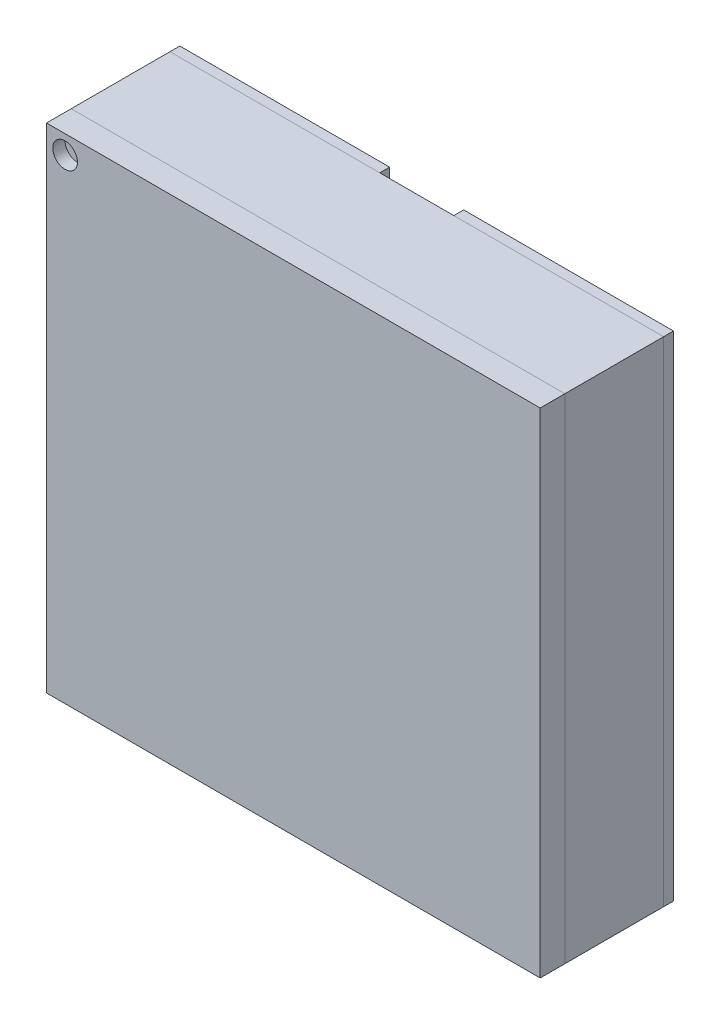
from build123d import *

# Parameters (mm, degrees)
MODEL_W               = 2
MODEL_H               = 2
BOSS_EXTRUDE1_DEPTH   = 0.4
SKETCH3_W             = 2
SKETCH3_H             = 2
BOSS_EXTRUDE2_DEPTH   = 0.1
SKETCH2_W             = 0.85
SKETCH2_H             = 2
BOSS_EXTRUDE3_DEPTH   = 0.04
BOSS_EXTRUDE3_2_DEPTH = 0.04
SKETCH4_R             = 0.05
CUT_EXTRUDE1_DEPTH    = 0.05
SKETCH6_R             = 0.2
CUT_EXTRUDE3_DEPTH    = 0.02


with BuildPart() as part:
    # Model → Boss-Extrude1 (new body)
    with BuildSketch(Plane.XY):
        with Locations((11.705, 88.295)):
            Rectangle(MODEL_W, MODEL_H)
    extrude(amount=BOSS_EXTRUDE1_DEPTH)


with BuildPart() as body_2:
    # Sketch3 → Boss-Extrude2 (new body)
    with BuildSketch(Plane.XY.offset(0.4)):
        with Locations((11.705, 88.295)):
            Rectangle(SKETCH3_W, SKETCH3_H)
    extrude(amount=BOSS_EXTRUDE2_DEPTH)

    # Sketch4 → Cut-Extrude1 (cut)
    with BuildSketch(Plane.XY.offset(0.5)):
        with Locations((10.780299021, 89.219700979)):
            Circle(SKETCH4_R)
    extrude(amount=-CUT_EXTRUDE1_DEPTH, mode=Mode.SUBTRACT)


with BuildPart() as body_3:
    # Sketch2 → Boss-Extrude3 (new body)
    with BuildSketch(Plane(origin=(0, 0, 0), x_dir=(-1, 0, 0), z_dir=(0, 0, -1))):
        with Locations((-11.13, 88.295)):
            Rectangle(SKETCH2_W, SKETCH2_H)
    extrude(amount=BOSS_EXTRUDE3_DEPTH)


with BuildPart() as body_4:
    # Sketch2 → Boss-Extrude3 2 (new body)
    with BuildSketch(Plane(origin=(0, 0, 0), x_dir=(-1, 0, 0), z_dir=(0, 0, -1))):
        with Locations((-12.28, 88.295)):
            Rectangle(SKETCH2_W, SKETCH2_H)
    extrude(amount=BOSS_EXTRUDE3_2_DEPTH)


with BuildPart() as cut_extrude3_tool:
    # Sketch6 → Cut-Extrude3 (new body)
    with BuildSketch(Plane(origin=(0, 0, -0.04), x_dir=(-1, 0, 0), z_dir=(0, 0, -1))):
        with Locations((-12.28, 88.895)):
            Circle(SKETCH6_R)
        with Locations(Location((-11.13, 88.895, 0), (0, 0, 180))):  # turned: the seam where the file's is
            Circle(SKETCH6_R)
    extrude(amount=-CUT_EXTRUDE3_DEPTH)


with BuildPart() as body_3_1:
    add(body_3.part)

    # Cut-Extrude3: cut by cut_extrude3_tool
    add(cut_extrude3_tool.part, mode=Mode.SUBTRACT)


with BuildPart() as body_4_1:
    add(body_4.part)

    # Cut-Extrude3: cut by cut_extrude3_tool
    add(cut_extrude3_tool.part, mode=Mode.SUBTRACT)


solid = Compound([part.part, body_2.part, body_3_1.part, body_4_1.part])
